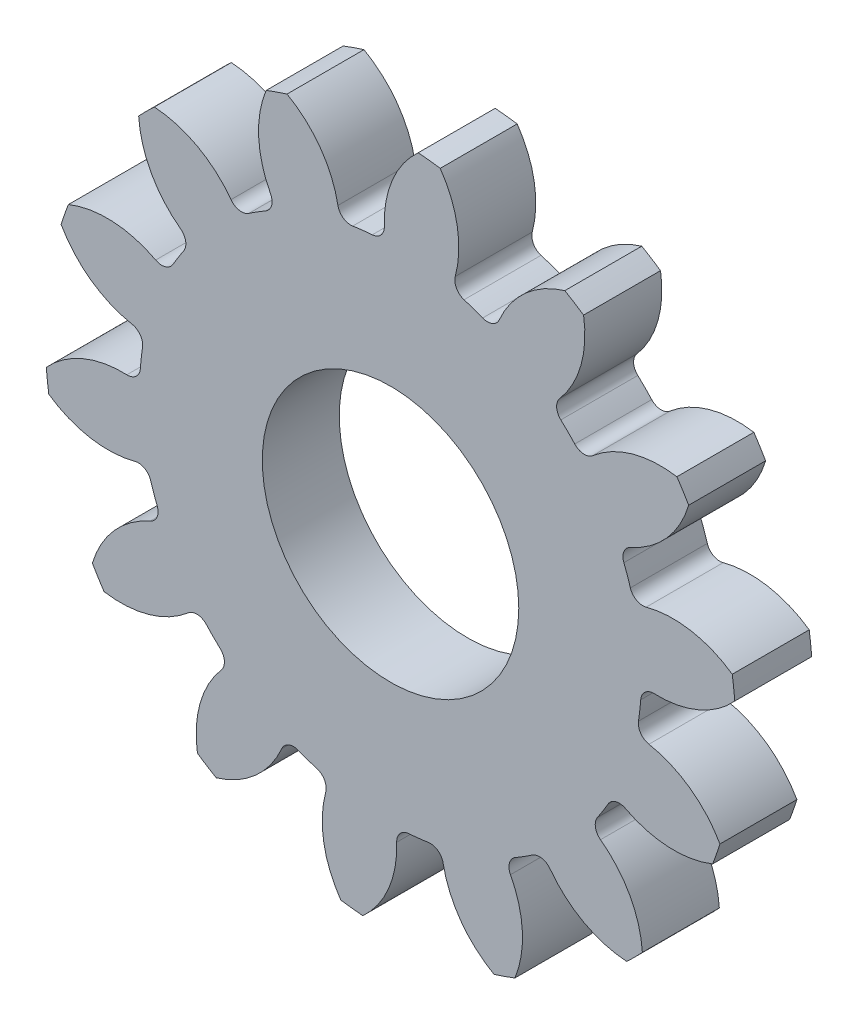
from build123d import *

# Parameters (mm, degrees)
CROQUIS1_R              = 13.462
SALIENTE_EXTRUIR1_DEPTH = 3
CORTAR_EXTRUIR1_DEPTH   = 4
REDONDEO1_R             = 0.508
MATRIZC1_COUNT          = 14
REDONDEO1_OF_MATRIZC1_R = 0.508
CROQUIS3_R              = 5
CORTAR_EXTRUIR2_DEPTH   = 4.0000001


with BuildPart() as part:
    # Croquis1 → Saliente-Extruir1 (new body)
    with BuildSketch(Plane.XY):
        Circle(CROQUIS1_R)
    extrude(amount=SALIENTE_EXTRUIR1_DEPTH)

    # Croquis2 → Cortar-Extruir1 (cut, through all)
    with BuildSketch(Plane.XY.offset(3)):
        with BuildLine():
            ThreePointArc((1.078935393, 13.418693767), (-1.505427957, 13.377560714), (-4.034295784, 12.84328235))
            ThreePointArc((-4.034295784, 12.84328235), (-2.595523839, 11.469191868), (-1.987151925, 9.574970926))
            ThreePointArc((-1.987151925, 9.574970926), (-1.093565591, 9.717662028), (-0.190615198, 9.777142059))
            ThreePointArc((-0.190615198, 9.777142059), (-0.018455647, 11.759199185), (1.078935393, 13.418693767))
        make_face()
    cortar_extruir1 = extrude(amount=-CORTAR_EXTRUIR1_DEPTH, mode=Mode.SUBTRACT)

    # Redondeo1
    redondeo1_edges = [part.edges().sort_by_distance(p)[0] for p in [
        (-0.190615198, 9.777142059, 1.5),
        (-1.987151925, 9.574970926, 1.5),
    ]]
    fillet(redondeo1_edges, radius=REDONDEO1_R)

    # MatrizC1: Cortar-Extruir1 ×14 about axis
    matrizc1_axis = Axis((0, 0, 0), (0, 0, 1))
    for i in range(1, MATRIZC1_COUNT):
        add(cortar_extruir1.rotate(matrizc1_axis, i * 360 / MATRIZC1_COUNT), mode=Mode.SUBTRACT)

    # Redondeo1 of MatrizC1
    redondeo1_of_matrizc1_edges = [part.edges().sort_by_distance(p)[0] for p in [
        (-4.413881314, 8.726195777, 1.5),
        (-5.944786207, 7.764557808, 1.5),
        (-7.762924103, 5.946919402, 1.5),
        (-8.724982673, 4.41627879, 1.5),
        (-9.574424567, 1.989782705, 1.5),
        (-9.777089316, 0.193301596, 1.5),
        (-9.489592823, -2.36145486, 1.5),
        (-8.892723511, -4.06796135, 1.5),
        (-7.525230838, -6.244977328, 1.5),
        (-6.247044753, -7.523514661, 1.5),
        (-4.070404595, -8.891605447, 1.5),
        (-2.364062167, -9.488943622, 1.5),
        (0.190615198, -9.777142059, 1.5),
        (1.987151925, -9.574970926, 1.5),
        (4.413881314, -8.726195777, 1.5),
        (5.944786207, -7.764557808, 1.5),
        (7.762924103, -5.946919402, 1.5),
        (8.724982673, -4.41627879, 1.5),
        (9.574424567, -1.989782705, 1.5),
        (9.777089316, -0.193301596, 1.5),
        (9.489592823, 2.36145486, 1.5),
        (8.892723511, 4.06796135, 1.5),
        (7.525230838, 6.244977328, 1.5),
        (6.247044753, 7.523514661, 1.5),
        (4.070404595, 8.891605447, 1.5),
        (2.364062167, 9.488943622, 1.5),
    ]]
    fillet(redondeo1_of_matrizc1_edges, radius=REDONDEO1_OF_MATRIZC1_R)

    # Croquis3 → Cortar-Extruir2 (cut, through all)
    with BuildSketch(Plane.XY.offset(3)):
        Circle(CROQUIS3_R)
    extrude(amount=-CORTAR_EXTRUIR2_DEPTH, mode=Mode.SUBTRACT)


solid = part.part
